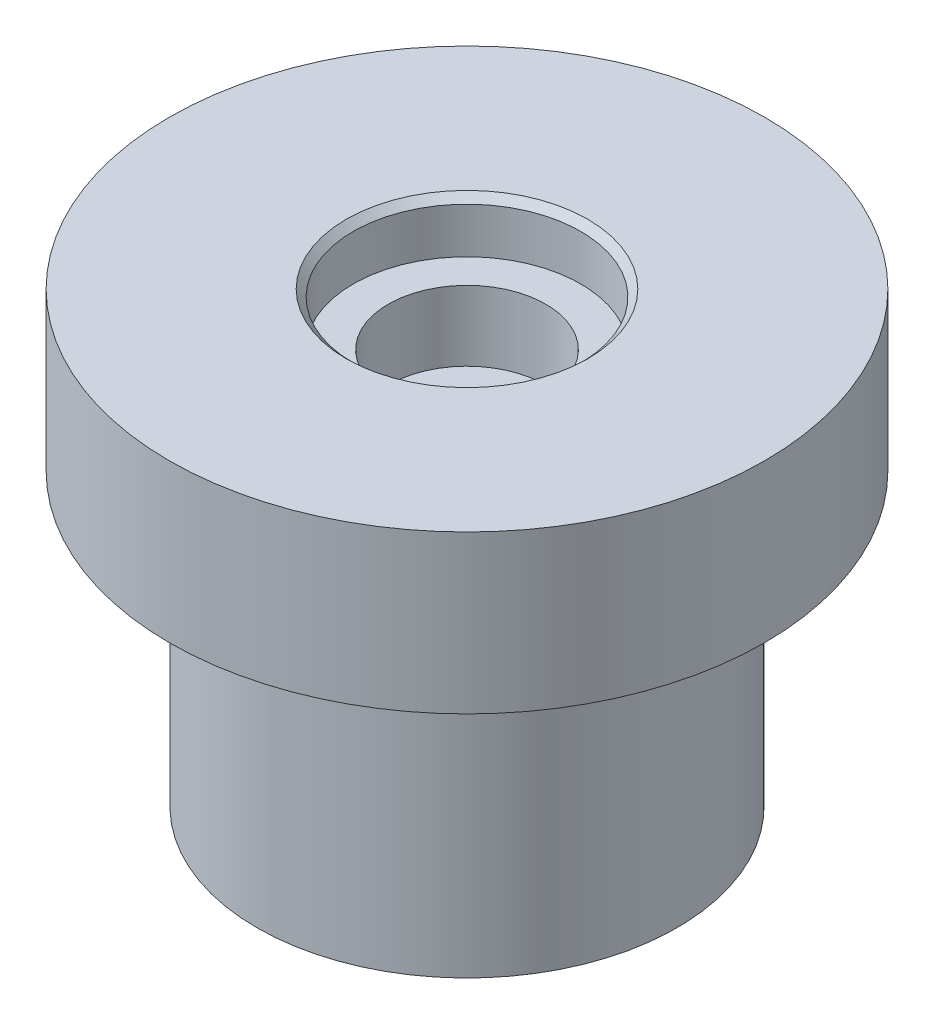
from build123d import *

# Parameters (mm, degrees)
SKETCH1_R           = 7
BOSS_EXTRUDE1_DEPTH = 12.8
SKETCH2_OUTSIDE_W   = 20.716
SKETCH2_OUTSIDE_H   = 20.716
SKETCH2_OUTSIDE_R   = 6
CUT_EXTRUDE1_DEPTH  = 13.8
SKETCH3_R           = 3.25
CUT_EXTRUDE2_DEPTH  = 1.5
SKETCH4_R           = 2.25
CUT_EXTRUDE3_DEPTH  = 2
CHAMFER1_SIZE       = 0.2
SKETCH_1_R          = 8.5
SKETCH_1_R_2        = 5.212411732
EXTRUDE_1_DEPTH     = 4.5


with BuildPart() as part:
    # Sketch1 → Boss-Extrude1 (new body)
    with BuildSketch(Plane(origin=(0, 0, 0), x_dir=(1, 0, 0), z_dir=(0, 1, 0))):
        Circle(SKETCH1_R)
    extrude(amount=BOSS_EXTRUDE1_DEPTH)

    # Sketch2 outside → Cut-Extrude1 (cut, through all)
    with BuildSketch(Plane.XZ):
        Rectangle(SKETCH2_OUTSIDE_W, SKETCH2_OUTSIDE_H)
        Circle(SKETCH2_OUTSIDE_R, mode=Mode.SUBTRACT)
    extrude(amount=-CUT_EXTRUDE1_DEPTH, mode=Mode.SUBTRACT)

    # Sketch3 → Cut-Extrude2 (cut)
    with BuildSketch(Plane(origin=(0, 12.8, 0), x_dir=(1, 0, 0), z_dir=(0, 1, 0))):
        Circle(SKETCH3_R)
    extrude(amount=-CUT_EXTRUDE2_DEPTH, mode=Mode.SUBTRACT)

    # Sketch4 → Cut-Extrude3 (cut)
    with BuildSketch(Plane(origin=(0, 11.3, 0), x_dir=(1, 0, 0), z_dir=(0, 1, 0))):
        Circle(SKETCH4_R)
    extrude(amount=-CUT_EXTRUDE3_DEPTH, mode=Mode.SUBTRACT)

    # Chamfer1
    chamfer1_edges = [part.edges().sort_by_distance(p)[0] for p in [
        (-3.25, 12.8, 0),
    ]]
    chamfer(chamfer1_edges, length=CHAMFER1_SIZE)

    # ｽｹｯﾁ1 → ﾎﾞｽ - 押し出し1 (add)
    with BuildSketch(Plane(origin=(0, 12.8, 0), x_dir=(1, 0, 0), z_dir=(0, 1, 0))):
        Circle(SKETCH_1_R)
        Circle(SKETCH_1_R_2, mode=Mode.SUBTRACT)
    extrude(amount=-EXTRUDE_1_DEPTH)


solid = part.part
